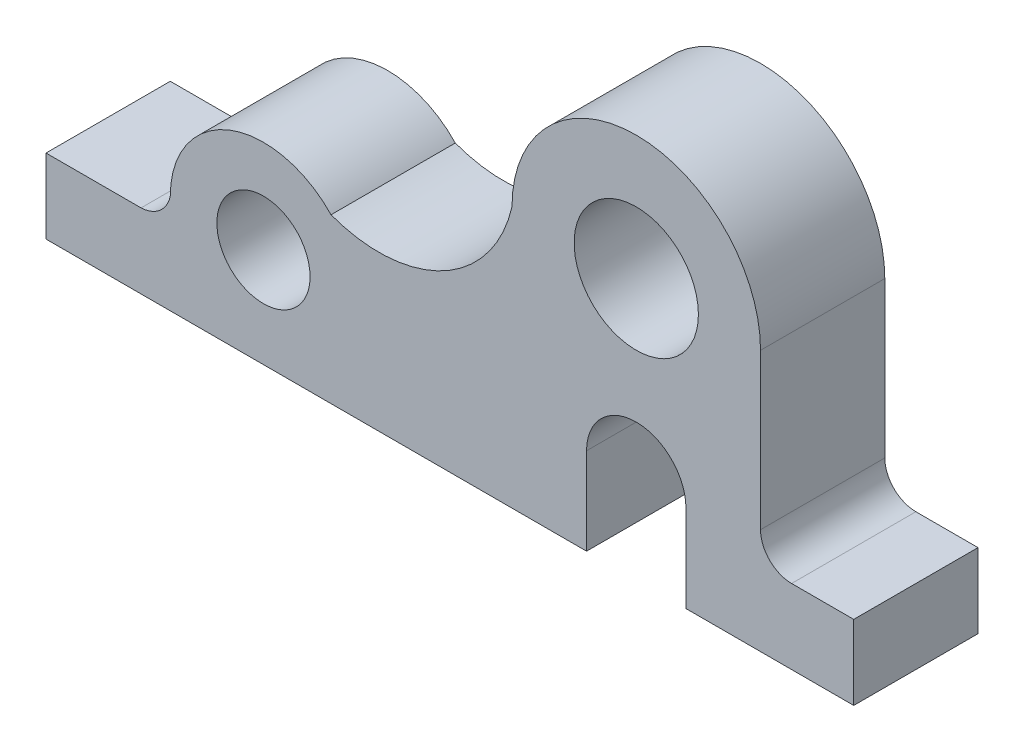
from build123d import *

# Parameters (mm, degrees)
SKETCH1_R           = 7.5
SKETCH1_R_2         = 10
BOSS_EXTRUDE1_DEPTH = 10


with BuildPart() as part:
    # Sketch1 → Boss-Extrude1 (new body, symmetric)
    with BuildSketch(Plane.XY):
        with BuildLine():
            Line((0, 0), (87, 0))
            Line((87, 0), (87, 14))
            ThreePointArc((87, 14), (95, 22), (103, 14))
            Line((103, 14), (103, 0))
            Line((103, 0), (130, 0))
            Line((130, 0), (130, 12))
            Line((130, 12), (120, 12))
            ThreePointArc((120, 12), (116.464466094, 13.464466094), (115, 17))
            Line((115, 17), (115, 42))
            ThreePointArc((115, 42), (95, 62), (75, 42))
            ThreePointArc((75, 42), (63.985563365, 27.57012052), (45.874646321, 26.331605267))
            ThreePointArc((45.874646321, 26.331605267), (29.43761269, 29.930536508), (20, 16))
            ThreePointArc((20, 16), (18.340800225, 13.188309736), (15.3, 12))
            Line((15.3, 12), (0, 12))
            Line((0, 12), (0, 0))
        make_face()
        with Locations((35, 16)):
            Circle(SKETCH1_R, mode=Mode.SUBTRACT)
        with Locations((95, 42)):
            Circle(SKETCH1_R_2, mode=Mode.SUBTRACT)
    extrude(amount=BOSS_EXTRUDE1_DEPTH, both=True)


solid = part.part
